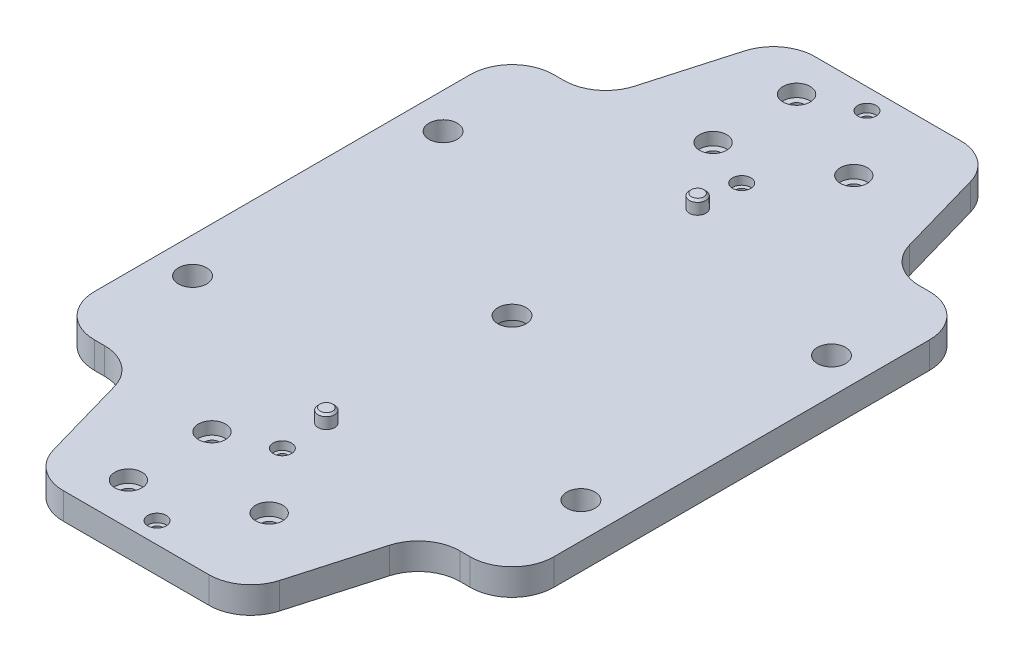
from build123d import *

# Parameters (mm, degrees)
BOSS_EXTRUDE1_DEPTH                              = 6.35
CBORE_FOR_1_4_SOCKET_HEAD_CAP_SCREW1_D           = 6.7564
CBORE_FOR_1_4_SOCKET_HEAD_CAP_SCREW1_CBORE_D     = 11.1125
CBORE_FOR_1_4_SOCKET_HEAD_CAP_SCREW1_CBORE_DEPTH = 2.999994
F_1_8_0_15625_PRESS_DOWEL_HOLE1_D                = 3.96875
SKETCH13_R                                       = 1.984375
BOSS_EXTRUDE4_DEPTH                              = 9.525
BOSS_EXTRUDE4_2_DEPTH                            = 9.525
CHAMFER1_SIZE                                    = 0.5
CHAMFER2_SIZE                                    = 0.5
SKETCH16_W                                       = 3.3782
SKETCH16_H                                       = 6.35
F_1_4_CLEARANCE_HOLE1_AT_2_COUNT                 = 2
F_1_4_CLEARANCE_HOLE1_AT_2_PITCH                 = 60
F_1_4_CLEARANCE_HOLE1_AT_3_COUNT                 = 2
F_1_4_CLEARANCE_HOLE1_AT_3_PITCH                 = 110.675200474
F_1_4_CLEARANCE_HOLE1_AT_4_COUNT                 = 2
F_1_4_CLEARANCE_HOLE1_AT_4_PITCH                 = 93
CBORE_FOR_M2_SHCS2_AT_2_COUNT                    = 2
CBORE_FOR_M2_SHCS2_AT_2_PITCH                    = 30
CBORE_FOR_M2_SHCS2_AT_3_COUNT                    = 2
CBORE_FOR_M2_SHCS2_AT_3_PITCH                    = 170
CBORE_FOR_M2_SHCS2_AT_4_COUNT                    = 2
CBORE_FOR_M2_SHCS2_AT_4_PITCH                    = 140
CBORE_FOR_M3_SHCS2_AT_2_COUNT                    = 2
CBORE_FOR_M3_SHCS2_AT_2_PITCH                    = 20
CBORE_FOR_M3_SHCS2_AT_3_COUNT                    = 2
CBORE_FOR_M3_SHCS2_AT_3_PITCH                    = 25.723335709
CBORE_FOR_M3_SHCS2_AT_4_COUNT                    = 2
CBORE_FOR_M3_SHCS2_AT_4_PITCH                    = 160
CBORE_FOR_M3_SHCS2_AT_5_COUNT                    = 2
CBORE_FOR_M3_SHCS2_AT_5_PITCH                    = 151.860758592
CBORE_FOR_M3_SHCS2_AT_6_COUNT                    = 2
CBORE_FOR_M3_SHCS2_AT_6_PITCH                    = 140
FILLET1_R                                        = 10


with BuildPart() as part:
    # Sketch1 → Boss-Extrude1 (new body)
    with BuildSketch(Plane(origin=(0, 0, 0), x_dir=(1, 0, 0), z_dir=(0, 1, 0))):
        Polygon((35, 55), (25, 90), (-25, 90), (-35, 55), (-55, 55), (-55, -55), (-35, -55), (-25, -90), (25, -90), (35, -55), (55, -55), (55, 55), align=None)
    extrude(amount=BOSS_EXTRUDE1_DEPTH)

    # CBORE for 1/4 Socket Head Cap Screw1 (through all)
    with Locations(Plane(origin=(0, 0, 0), x_dir=(-1, 0, 0), z_dir=(0, -1, 0))):
        with Locations((0, 0)):
            CounterBoreHole(CBORE_FOR_1_4_SOCKET_HEAD_CAP_SCREW1_D / 2, CBORE_FOR_1_4_SOCKET_HEAD_CAP_SCREW1_CBORE_D / 2, CBORE_FOR_1_4_SOCKET_HEAD_CAP_SCREW1_CBORE_DEPTH)

    # 1/8 (0.15625) Press Dowel Hole1 (through all)
    with Locations(Plane(origin=(0, 6.35, 0), x_dir=(1, 0, 0), z_dir=(0, 1, 0))):
        with Locations((0, 44.45), (0, -44.45)):
            Hole(F_1_8_0_15625_PRESS_DOWEL_HOLE1_D / 2)

    # Sketch16 → 1/4 Clearance Hole1 (revolve, cut)
    with BuildSketch(Plane(origin=(-46.5, 0, -30), x_dir=(0, 0, -1), z_dir=(1, 0, 0))):
        with Locations((1.6891, 3.175)):
            Rectangle(SKETCH16_W, SKETCH16_H)
    f_1_4_clearance_hole1 = revolve(axis=Axis((-46.5, -6.35, -30), (0, 1, 0)), mode=Mode.SUBTRACT)

    # 1/4 Clearance Hole1 at 2: 1/4 Clearance Hole1 ×2
    with Locations(*[(0, 0, i * F_1_4_CLEARANCE_HOLE1_AT_2_PITCH) for i in range(1, F_1_4_CLEARANCE_HOLE1_AT_2_COUNT)]):
        add(f_1_4_clearance_hole1, mode=Mode.SUBTRACT)

    # 1/4 Clearance Hole1 at 3: 1/4 Clearance Hole1 ×2
    with Locations(*[Vector(0.840296648, 0, 0.54212687) * (i * F_1_4_CLEARANCE_HOLE1_AT_3_PITCH) for i in range(1, F_1_4_CLEARANCE_HOLE1_AT_3_COUNT)]):
        add(f_1_4_clearance_hole1, mode=Mode.SUBTRACT)

    # 1/4 Clearance Hole1 at 4: 1/4 Clearance Hole1 ×2
    with Locations(*[(i * F_1_4_CLEARANCE_HOLE1_AT_4_PITCH, 0, 0) for i in range(1, F_1_4_CLEARANCE_HOLE1_AT_4_COUNT)]):
        add(f_1_4_clearance_hole1, mode=Mode.SUBTRACT)

    # Sketch22 → CBORE for M2 SHCS2 (revolve, cut)
    with BuildSketch(Plane(origin=(0, 6.35, -85), x_dir=(0, 0, 1), z_dir=(1, 0, 0))):
        Polygon((0, 0), (0, 6.35), (1.3, 6.35), (1.3, 2), (2.2, 2), (2.2, 0), align=None)
    cbore_for_m2_shcs2 = revolve(axis=Axis((0, 12.7, -85), (0, -1, 0)), mode=Mode.SUBTRACT)

    # CBORE for M2 SHCS2 at 2: CBORE for M2 SHCS2 ×2
    with Locations(*[(0, 0, i * CBORE_FOR_M2_SHCS2_AT_2_PITCH) for i in range(1, CBORE_FOR_M2_SHCS2_AT_2_COUNT)]):
        add(cbore_for_m2_shcs2, mode=Mode.SUBTRACT)

    # CBORE for M2 SHCS2 at 3: CBORE for M2 SHCS2 ×2
    with Locations(*[(0, 0, i * CBORE_FOR_M2_SHCS2_AT_3_PITCH) for i in range(1, CBORE_FOR_M2_SHCS2_AT_3_COUNT)]):
        add(cbore_for_m2_shcs2, mode=Mode.SUBTRACT)

    # CBORE for M2 SHCS2 at 4: CBORE for M2 SHCS2 ×2
    with Locations(*[(0, 0, i * CBORE_FOR_M2_SHCS2_AT_4_PITCH) for i in range(1, CBORE_FOR_M2_SHCS2_AT_4_COUNT)]):
        add(cbore_for_m2_shcs2, mode=Mode.SUBTRACT)

    # Sketch24 → CBORE for M3 SHCS2 (revolve, cut)
    with BuildSketch(Plane(origin=(-11.85, 6.35, -80), x_dir=(0, 0, 1), z_dir=(1, 0, 0))):
        Polygon((0, 0), (0, 6.35), (1.8, 6.35), (1.8, 3), (3.25, 3), (3.25, 0), align=None)
    cbore_for_m3_shcs2 = revolve(axis=Axis((-11.85, 12.7, -80), (0, -1, 0)), mode=Mode.SUBTRACT)

    # CBORE for M3 SHCS2 at 2: CBORE for M3 SHCS2 ×2
    with Locations(*[(0, 0, i * CBORE_FOR_M3_SHCS2_AT_2_PITCH) for i in range(1, CBORE_FOR_M3_SHCS2_AT_2_COUNT)]):
        add(cbore_for_m3_shcs2, mode=Mode.SUBTRACT)

    # CBORE for M3 SHCS2 at 3: CBORE for M3 SHCS2 ×2
    with Locations(*[Vector(0.921342406, 0, 0.38875207) * (i * CBORE_FOR_M3_SHCS2_AT_3_PITCH) for i in range(1, CBORE_FOR_M3_SHCS2_AT_3_COUNT)]):
        add(cbore_for_m3_shcs2, mode=Mode.SUBTRACT)

    # CBORE for M3 SHCS2 at 4: CBORE for M3 SHCS2 ×2
    with Locations(*[(0, 0, i * CBORE_FOR_M3_SHCS2_AT_4_PITCH) for i in range(1, CBORE_FOR_M3_SHCS2_AT_4_COUNT)]):
        add(cbore_for_m3_shcs2, mode=Mode.SUBTRACT)

    # CBORE for M3 SHCS2 at 5: CBORE for M3 SHCS2 ×2
    with Locations(*[Vector(0.156064017, 0, 0.987746943) * (i * CBORE_FOR_M3_SHCS2_AT_5_PITCH) for i in range(1, CBORE_FOR_M3_SHCS2_AT_5_COUNT)]):
        add(cbore_for_m3_shcs2, mode=Mode.SUBTRACT)

    # CBORE for M3 SHCS2 at 6: CBORE for M3 SHCS2 ×2
    with Locations(*[(0, 0, i * CBORE_FOR_M3_SHCS2_AT_6_PITCH) for i in range(1, CBORE_FOR_M3_SHCS2_AT_6_COUNT)]):
        add(cbore_for_m3_shcs2, mode=Mode.SUBTRACT)

    # Fillet1
    fillet1_edges = [part.edges().sort_by_distance(p)[0] for p in [
        (-55, 3.175, -55),
        (-35, 3.175, -55),
        (-25, 3.175, -90),
        (25, 3.175, -90),
        (35, 3.175, -55),
        (55, 3.175, -55),
        (55, 3.175, 55),
        (35, 3.175, 55),
        (25, 3.175, 90),
        (-25, 3.175, 90),
        (-35, 3.175, 55),
        (-55, 3.175, 55),
    ]]
    fillet(fillet1_edges, radius=FILLET1_R)


with BuildPart() as body_2:
    # Sketch13 → Boss-Extrude4 (new body)
    with BuildSketch(Plane(origin=(0, 0, 0), x_dir=(1, 0, 0), z_dir=(0, 1, 0))):
        with Locations((0, -44.45)):
            Circle(SKETCH13_R)
    extrude(amount=BOSS_EXTRUDE4_DEPTH)

    # Chamfer1
    chamfer1_edges = [body_2.edges().sort_by_distance(p)[0] for p in [
        (-1.984375, 0, 44.45),
        (-1.984375, 9.525, 44.45),
    ]]
    chamfer(chamfer1_edges, length=CHAMFER1_SIZE)


with BuildPart() as body_3:
    # Sketch13 → Boss-Extrude4 2 (new body)
    with BuildSketch(Plane(origin=(0, 0, 0), x_dir=(1, 0, 0), z_dir=(0, 1, 0))):
        with Locations((0, 44.45)):
            Circle(SKETCH13_R)
    extrude(amount=BOSS_EXTRUDE4_2_DEPTH)

    # Chamfer2
    chamfer2_edges = [body_3.edges().sort_by_distance(p)[0] for p in [
        (-1.984375, 0, -44.45),
        (-1.984375, 9.525, -44.45),
    ]]
    chamfer(chamfer2_edges, length=CHAMFER2_SIZE)


solid = Compound([part.part, body_2.part, body_3.part])
